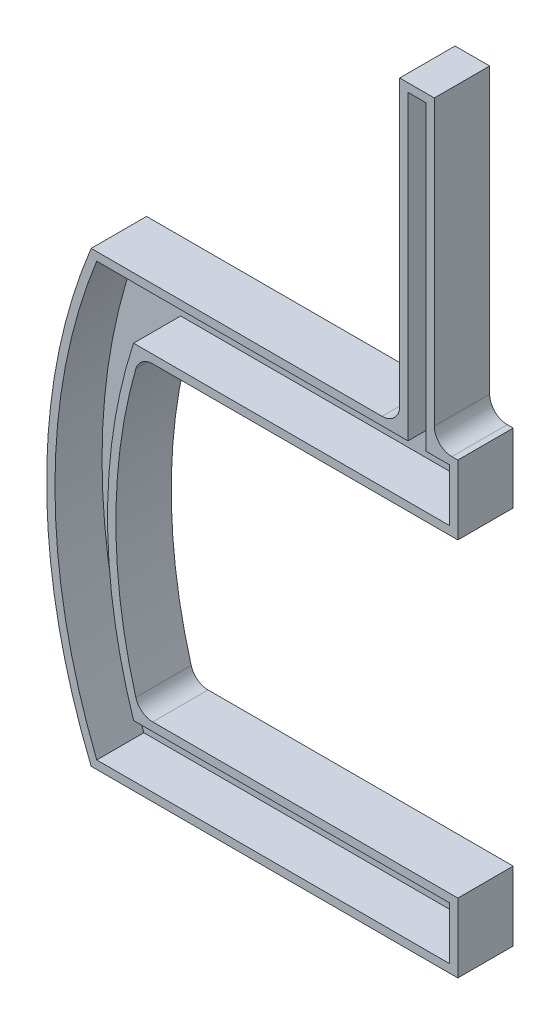
from build123d import *

# Parameters (mm, degrees)
BOSS_EXTRUDE1_DEPTH = 20
CUT_EXTRUDE1_DEPTH  = 17
FILLET1_R           = 6.35


with BuildPart() as part:
    # Sketch1 → Boss-Extrude1 (new body)
    with BuildSketch(Plane.XY):
        with BuildLine():
            Line((-195.91579824, 81), (-84.5, 81))
            Line((-84.5, 81), (-84.5, 190))
            Line((-84.5, 190), (-72, 190))
            Line((-72, 190), (-72, 81))
            Line((-72, 81), (-63.5, 81))
            Line((-63.5, 81), (-63.5, 56))
            Line((-63.5, 56), (-178.418048414, 56))
            ThreePointArc((-178.418048414, 56), (-187, 0), (-178.418048414, -56))
            Line((-178.418048414, -56), (-63.5, -56))
            Line((-63.5, -56), (-63.5, -81))
            Line((-63.5, -81), (-195.91579824, -81))
            ThreePointArc((-195.91579824, -81), (-212, 0), (-195.91579824, 81))
        make_face()
    extrude(amount=BOSS_EXTRUDE1_DEPTH)

    # Sketch2 → Cut-Extrude1 (cut)
    with BuildSketch(Plane.XY.offset(20)):
        with BuildLine():
            Line((-66.5, 78), (-75, 78))
            Line((-75, 78), (-75, 187))
            Line((-75, 187), (-81.5, 187))
            Line((-81.5, 187), (-81.5, 78))
            Line((-81.5, 78), (-193.899458483, 78))
            ThreePointArc((-193.899458483, 78), (-209, 0), (-193.899458483, -78))
            Line((-193.899458483, -78), (-66.5, -78))
            Line((-66.5, -78), (-66.5, -59))
            Line((-66.5, -59), (-180.607308822, -59))
            ThreePointArc((-180.607308822, -59), (-190, 0), (-180.607308822, 59))
            Line((-180.607308822, 59), (-66.5, 59))
            Line((-66.5, 59), (-66.5, 78))
        make_face()
    extrude(amount=-CUT_EXTRUDE1_DEPTH, mode=Mode.SUBTRACT)

    # Fillet1
    fillet1_edges = [part.edges().sort_by_distance(p)[0] for p in [
        (-178.418048414, 56, 10),
        (-178.418048414, -56, 10),
        (-84.5, 81, 10),
        (-72, 81, 10),
    ]]
    fillet(fillet1_edges, radius=FILLET1_R)


solid = part.part
